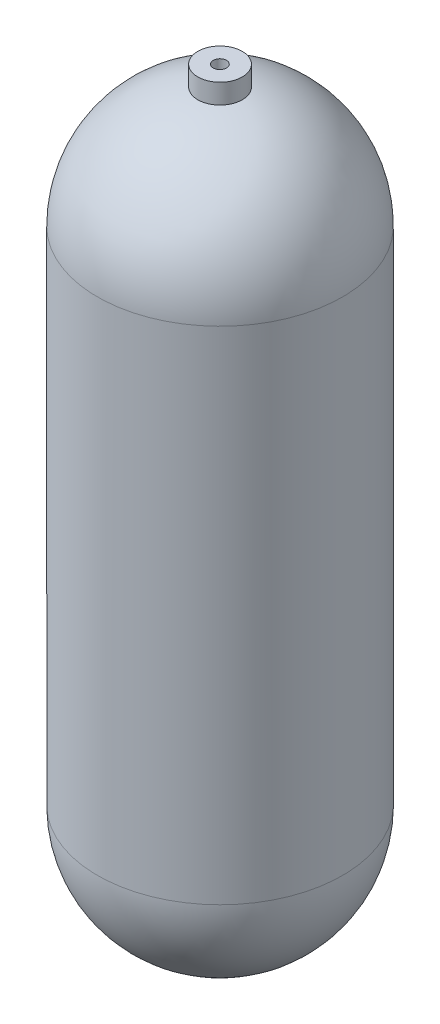
from build123d import *

# Parameters (mm, degrees)
SKETCH2_R                        = 15.875
BOSS_EXTRUDE1_DEPTH              = 12.7
BOSS_EXTRUDE1_DIRECTION_2_REACH  = 535.4
F_3_8_0_375_DIAMETER_HOLE1_D     = 9.525
F_3_8_0_375_DIAMETER_HOLE1_DEPTH = 25.4
F_3_8_0_375_DIAMETER_HOLE1_TIP   = 2.861599


with BuildPart() as part:
    # Sketch1 → Revolve1 (revolve)
    with BuildSketch(Plane.XY):
        with BuildLine():
            Line((87.63, 445.77), (87.63, 87.63))
            ThreePointArc((87.63, 87.63), (61.963767, 25.666233), (0, 0))
            Line((0, 0), (0, 3.175))
            ThreePointArc((0, 3.175), (59.718703, 27.911297), (84.455, 87.63))
            Line((84.455, 87.63), (84.455, 445.77))
            ThreePointArc((84.455, 445.77), (59.718703, 505.488703), (0, 530.225))
            Line((0, 530.225), (0, 533.4))
            ThreePointArc((0, 533.4), (61.963767, 507.733767), (87.63, 445.77))
        make_face()
    revolve(axis=Axis((0, 533.4, 0), (0, 1, 0)))

    # Sketch2 → Boss-Extrude1 (add)
    with BuildSketch(Plane(origin=(0, 533.4, 0), x_dir=(1, 0, 0), z_dir=(0, 1, 0))):
        Circle(SKETCH2_R)
    extrude(amount=BOSS_EXTRUDE1_DEPTH)

    # Sketch2 → Boss-Extrude1 direction 2 (add, up to next)
    with BuildSketch(Plane(origin=(0, 533.4, 0), x_dir=(1, 0, 0), z_dir=(0, 1, 0)), mode=Mode.PRIVATE) as boss_extrude1_direction_2_sk1:
        Circle(SKETCH2_R)
    boss_extrude1_direction_2_tool1 = extrude(boss_extrude1_direction_2_sk1.sketch, amount=-BOSS_EXTRUDE1_DIRECTION_2_REACH, mode=Mode.PRIVATE) - part.part
    add(boss_extrude1_direction_2_tool1.solids().sort_by_distance((0, 533.4, 0))[0])

    # 3/8 (0.375) Diameter Hole1
    with Locations(Plane(origin=(-0.053239, 546.1, 0.093777), x_dir=(0, 0, 1), z_dir=(0, 1, 0))):
        with Locations((0, 0)):
            Hole(F_3_8_0_375_DIAMETER_HOLE1_D / 2, depth=F_3_8_0_375_DIAMETER_HOLE1_DEPTH)
            with Locations((0, 0, -(F_3_8_0_375_DIAMETER_HOLE1_DEPTH + F_3_8_0_375_DIAMETER_HOLE1_TIP / 2))):  # 118° drill point
                Cone(0, F_3_8_0_375_DIAMETER_HOLE1_D / 2, F_3_8_0_375_DIAMETER_HOLE1_TIP, mode=Mode.SUBTRACT)


solid = part.part
